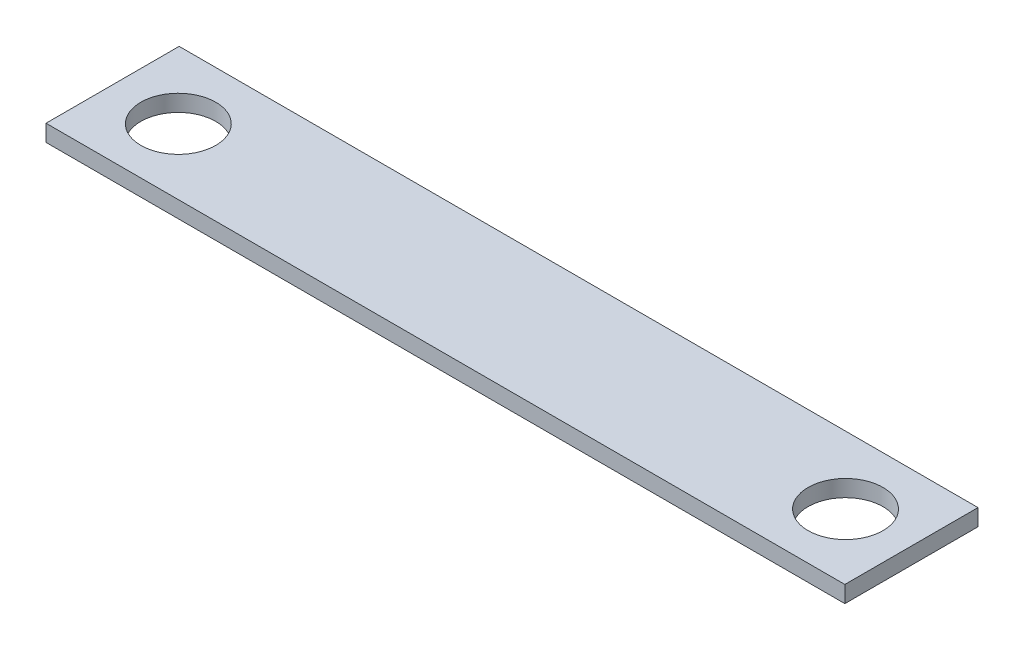
from build123d import *

# Parameters (mm, degrees)
SKETCH1_W           = 304.8
SKETCH1_H           = 50.8
BOSS_EXTRUDE1_DEPTH = 6.35
SKETCH2_R           = 14.2875
CUT_EXTRUDE1_DEPTH  = 6.35


with BuildPart() as part:
    # Sketch1 → Boss-Extrude1 (new body)
    with BuildSketch(Plane(origin=(0, 0, 0), x_dir=(1, 0, 0), z_dir=(0, 1, 0))):
        with Locations((14.553513514, 22.379459459)):
            Rectangle(SKETCH1_W, SKETCH1_H)
    extrude(amount=BOSS_EXTRUDE1_DEPTH)

    # Sketch2 → Cut-Extrude1 (cut)
    with BuildSketch(Plane(origin=(0, 6.35, 0), x_dir=(1, 0, 0), z_dir=(0, 1, 0))):
        with Locations((-112.415422729, 22.027621865)):
            Circle(SKETCH2_R)
        with Locations((142.165858982, 22.027621865)):
            Circle(SKETCH2_R)
    extrude(amount=-CUT_EXTRUDE1_DEPTH, mode=Mode.SUBTRACT)


solid = part.part
